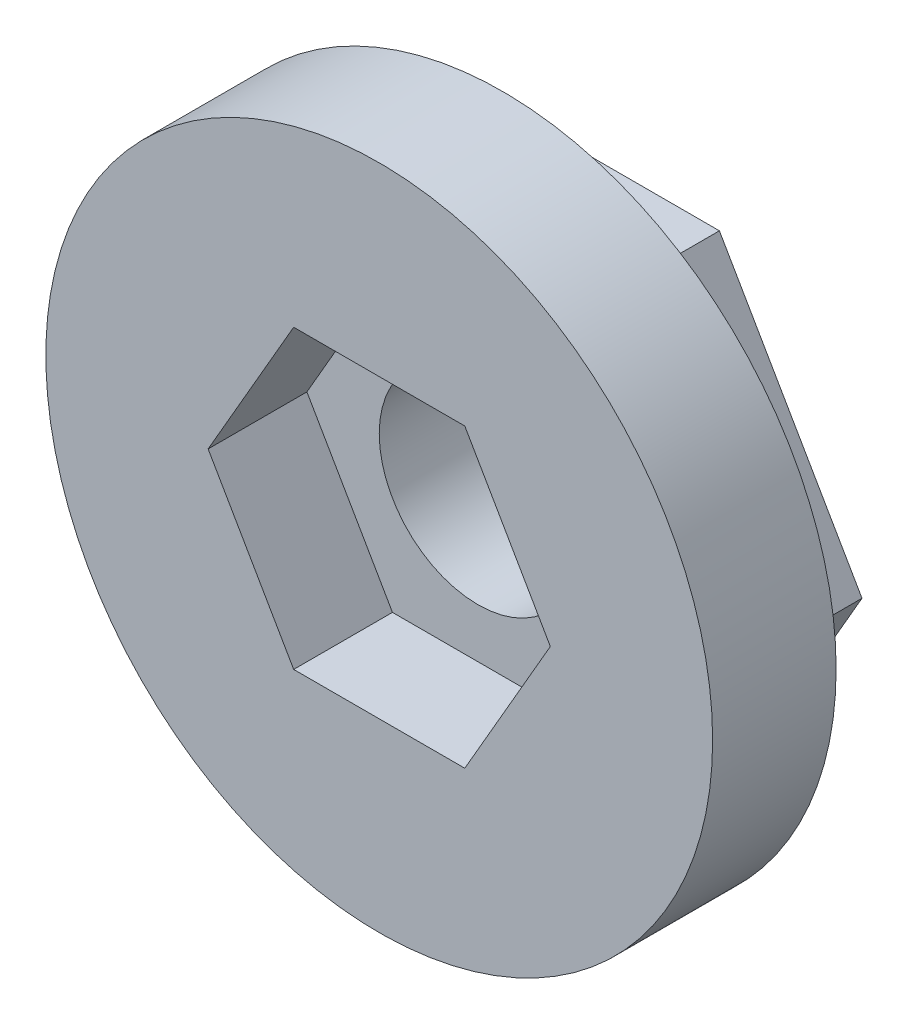
from build123d import *

# Parameters (mm, degrees)
BOSS_EXTRUDE1_DEPTH = 3
SKETCH3_R           = 13.5
BOSS_EXTRUDE2_DEPTH = 5
CUT_EXTRUDE1_DEPTH  = 4
SKETCH6_R           = 4
CUT_EXTRUDE2_DEPTH  = 9


with BuildPart() as part:
    # Sketch1 → Boss-Extrude1 (new body)
    with BuildSketch(Plane.XY):
        Polygon((11.547005384, 0), (5.773502692, 10), (-5.773502692, 10), (-11.547005384, 0), (-5.773502692, -10), (5.773502692, -10), align=None)
    extrude(amount=BOSS_EXTRUDE1_DEPTH)

    # Sketch3 → Boss-Extrude2 (add)
    with BuildSketch(Plane.XY.offset(3)):
        Circle(SKETCH3_R)
    extrude(amount=BOSS_EXTRUDE2_DEPTH)

    # Sketch4 → Cut-Extrude1 (cut)
    with BuildSketch(Plane.XY.offset(8)):
        Polygon((3.464101615, -6), (6.92820323, 0), (3.464101615, 6), (-3.464101615, 6), (-6.92820323, 0), (-3.464101615, -6), align=None)
    extrude(amount=-CUT_EXTRUDE1_DEPTH, mode=Mode.SUBTRACT)

    # Sketch6 → Cut-Extrude2 (cut, through all)
    with BuildSketch(Plane(origin=(0, 0, 0), x_dir=(-1, 0, 0), z_dir=(0, 0, -1))):
        Circle(SKETCH6_R)
    extrude(amount=-CUT_EXTRUDE2_DEPTH, mode=Mode.SUBTRACT)


solid = part.part
